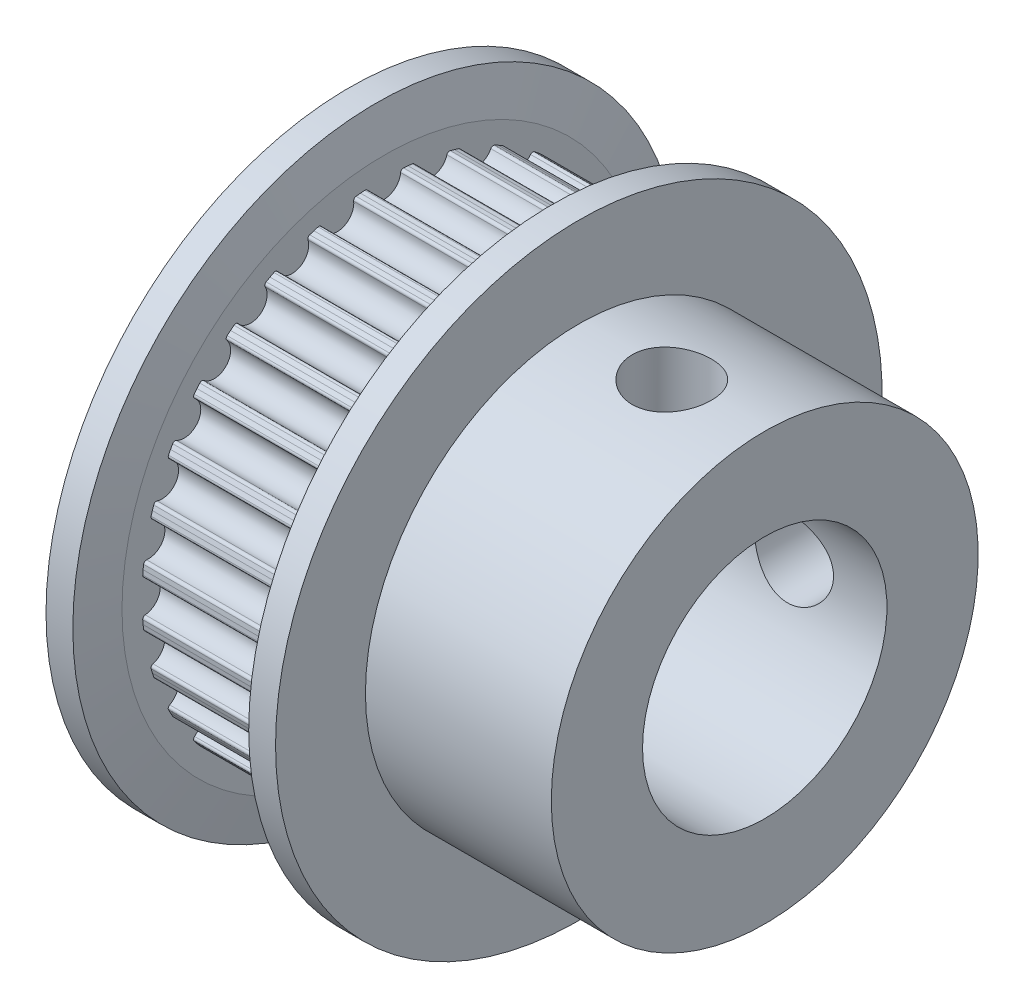
from build123d import *

# Parameters (mm, degrees)
CUT_EXTRUDE1_DEPTH = 6.55
CIRPATTERN1_COUNT  = 32
SKETCH39_R         = 5.01
CUT_EXTRUDE2_DEPTH = 17.03
SKETCH37_W         = 1.621
SKETCH37_H         = 9.93
CIRPATTERN2_COUNT  = 2
CIRPATTERN2_ANGLE  = 90


with BuildPart() as part:
    # Sketch1 → Revolve1 (revolve)
    with BuildSketch(Plane.XY):
        Polygon((0, 0), (0, 8.75), (1.43, 8.75), (1.43, 10.088071429), (7.98, 10.088071429), (7.98, 8.75), (17.03, 8.75), (17.03, 0), align=None)
    revolve(axis=Axis((17.03, 0, 0), (-1, 0, 0)))

    # Sketch2 → Cut-Extrude1 (cut)
    with BuildSketch(Plane(origin=(1.43, 0, 0), x_dir=(0, 0, -1), z_dir=(1, 0, 0))):
        with BuildLine():
            Line((-1.03437385, 9.879953537), (-1.057813893, 10.129918794))
            ThreePointArc((-1.057813893, 10.129918794), (0, 10.185), (1.057813893, 10.129918794))
            Line((1.057813893, 10.129918794), (1.03437385, 9.879953537))
            Line((1.03437385, 9.879953537), (0.792969158, 9.89929093))
            ThreePointArc((0.792969158, 9.89929093), (0.711706777, 9.87316989), (0.672449407, 9.797375812))
            ThreePointArc((0.672449407, 9.797375812), (0, 9.181), (-0.672449407, 9.797375812))
            ThreePointArc((-0.672449407, 9.797375812), (-0.711706777, 9.87316989), (-0.792969158, 9.89929093))
            Line((-0.792969158, 9.89929093), (-1.03437385, 9.879953537))
        make_face()
    cut_extrude1 = extrude(amount=CUT_EXTRUDE1_DEPTH, mode=Mode.SUBTRACT)

    # CirPattern1: Cut-Extrude1 ×32 about axis
    cirpattern1_axis = Axis((0, 0, 0), (1, 0, 0))
    for i in range(1, CIRPATTERN1_COUNT):
        add(cut_extrude1.rotate(cirpattern1_axis, i * 360 / CIRPATTERN1_COUNT), mode=Mode.SUBTRACT)

    # Sketch34 → Revolve2 (revolve)
    with BuildSketch(Plane.XY):
        Polygon((7.98, 8.75), (7.98, 10.75), (8.31, 12.435), (9.41, 12.435), (9.41, 8.75), align=None)
        Polygon((1.43, 8.75), (1.43, 10.75), (1.1, 12.435), (0, 12.435), (0, 8.76), (0.01, 8.75), align=None)
    revolve(axis=Axis((17.03, 0, 0), (-1, 0, 0)))

    # Sketch39 → Cut-Extrude2 (cut)
    with BuildSketch(Plane.ZY):
        Circle(SKETCH39_R)
    extrude(amount=-CUT_EXTRUDE2_DEPTH, mode=Mode.SUBTRACT)

    # Sketch37 → Cut-Revolve2 (revolve, cut)
    with BuildSketch(Plane(origin=(13.22, 0, 0), x_dir=(0, 0, -1), z_dir=(1, 0, 0))):
        with Locations((0.8105, 4.965)):
            Rectangle(SKETCH37_W, SKETCH37_H)
    cut_revolve2 = revolve(axis=Axis((13.22, 0, 0), (0, 1, 0)), mode=Mode.SUBTRACT)

    # CirPattern2: Cut-Revolve2 ×2 about axis
    cirpattern2_axis = Axis((17.03, 0, 0), (-1, 0, 0))
    for i in range(1, CIRPATTERN2_COUNT):
        add(cut_revolve2.rotate(cirpattern2_axis, i * CIRPATTERN2_ANGLE / (CIRPATTERN2_COUNT - 1)), mode=Mode.SUBTRACT)


solid = part.part
